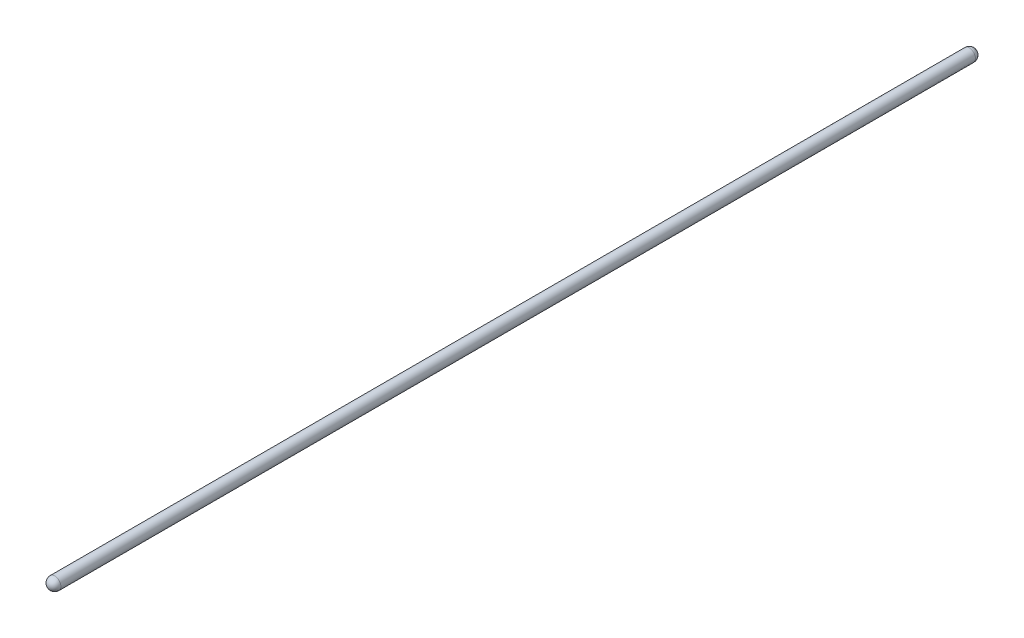
from build123d import *


with BuildPart() as part:
    # Sketch1 → Revolve1 (revolve)
    with BuildSketch(Plane(origin=(0, 0, 0), x_dir=(1, 0, 0), z_dir=(0, 1, 0))):
        with BuildLine():
            Line((9.525, 0), (9.525, -1411.72311))
            ThreePointArc((9.525, -1411.72311), (6.735192091, -1418.458302091), (0, -1421.24811))
            Line((0, -1421.24811), (0, 9.525))
            ThreePointArc((0, 9.525), (6.735192091, 6.735192091), (9.525, 0))
        make_face()
    revolve(axis=Axis((0, 0, -9.525), (0, 0, 1)))


solid = part.part
